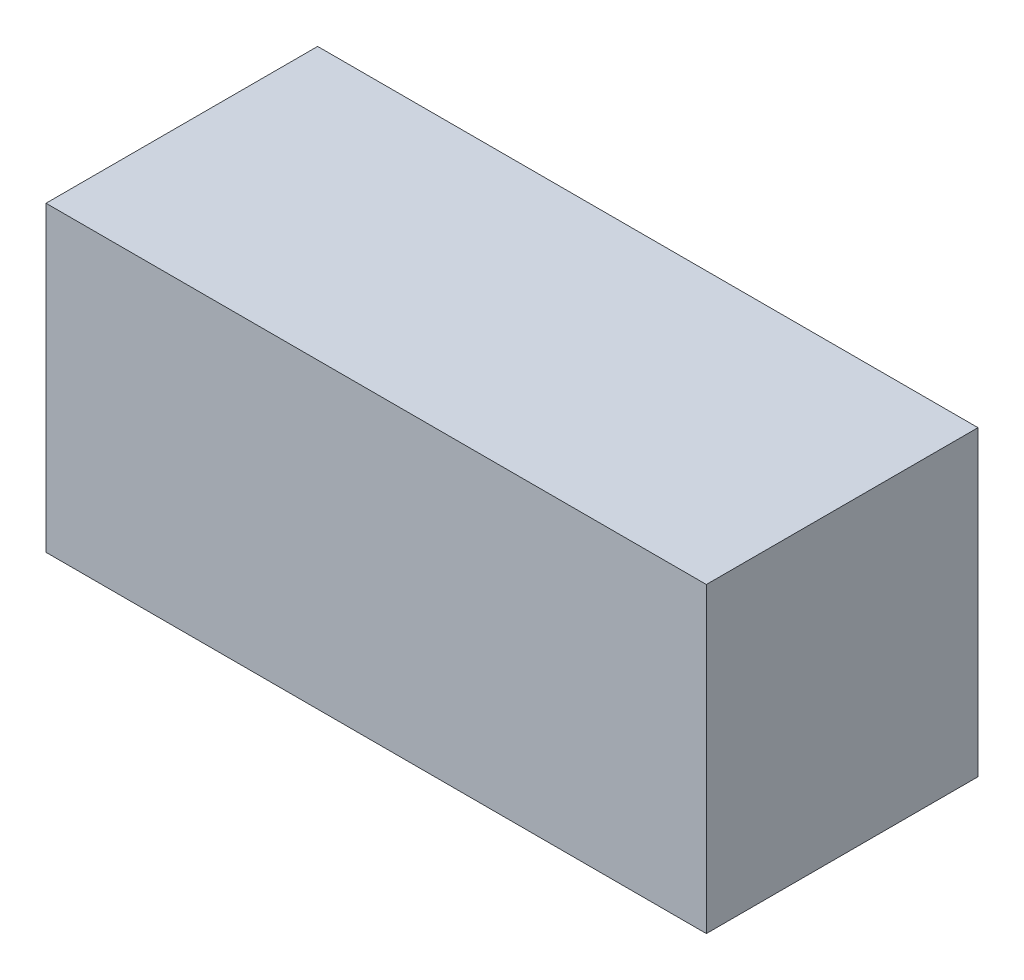
from build123d import *

# Parameters (mm, degrees)
SKETCH1_W           = 48.62
SKETCH1_H           = 22.26
BOSS_EXTRUDE1_DEPTH = 20


with BuildPart() as part:
    # Sketch1 → Boss-Extrude1 (new body)
    with BuildSketch(Plane.XY):
        Rectangle(SKETCH1_W, SKETCH1_H)
    extrude(amount=BOSS_EXTRUDE1_DEPTH)


solid = part.part
